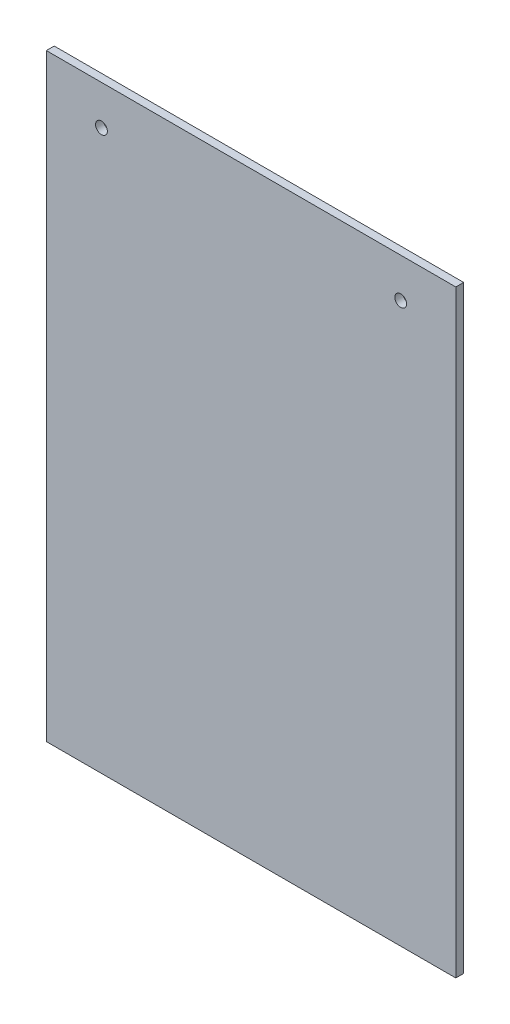
from build123d import *

# Parameters (mm, degrees)
SKETCH1_W                    = 330.2
SKETCH1_H                    = 482.6
BOSS_EXTRUDE1_DEPTH          = 6.35
F_3_8_0_375_DIAMETER_HOLE1_D = 9.525


with BuildPart() as part:
    # Sketch1 → Boss-Extrude1 (new body)
    with BuildSketch(Plane.XY):
        with Locations((165.1, 241.3)):
            Rectangle(SKETCH1_W, SKETCH1_H)
    extrude(amount=BOSS_EXTRUDE1_DEPTH)

    # 3/8 (0.375) Diameter Hole1 (through all)
    with Locations(Plane.XY.offset(6.35)):
        with Locations((44.45, 450.85), (285.75, 450.85)):
            Hole(F_3_8_0_375_DIAMETER_HOLE1_D / 2)


solid = part.part
